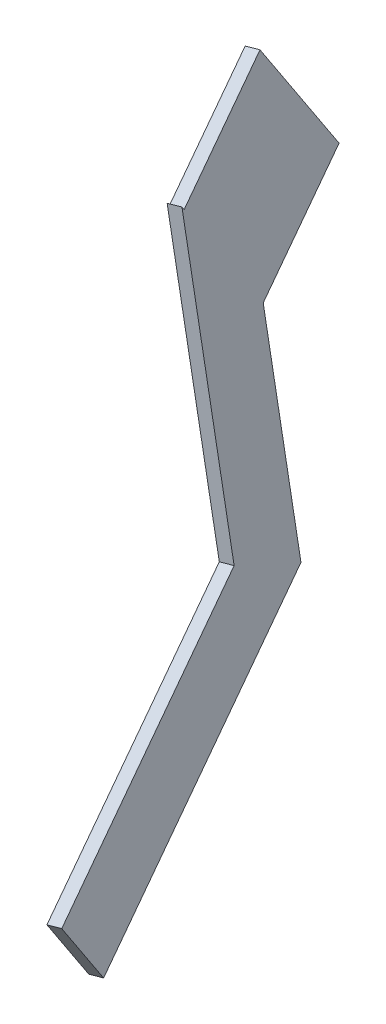
from build123d import *

# Parameters (mm, degrees)
BOSS_EXTRUDE1_DEPTH = 5


with BuildPart() as part:
    # Sketch1 → Boss-Extrude1 (new body)
    with BuildSketch(Plane(origin=(-68.393987025, -9.003975274, 13.699403605), x_dir=(0.193117752, 0.025423689, 0.98084615), z_dir=(-0.972455361, -0.128022424, 0.19478406))):
        Polygon((94.9260126, -386.995373369), (88.574683282, -506.05602004), (185.581785057, -571.620177961), (168.782752396, -596.475609996), (57.713123785, -521.407016695), (62.308943144, -435.254780286), (19.608153336, -406.394611545), (51.352814744, -359.425997935), (94.053604552, -388.286166677), align=None)
    extrude(amount=-BOSS_EXTRUDE1_DEPTH)


solid = part.part
